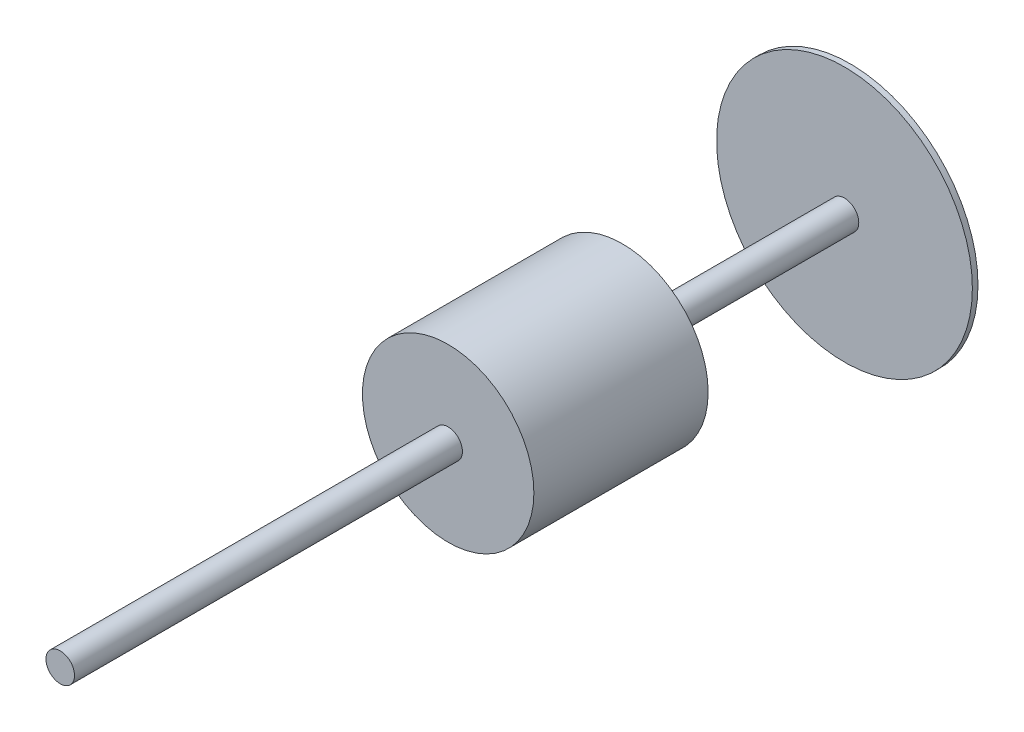
from build123d import *

# Parameters (mm, degrees)
SKETCH1_R                = 50.8
BOSS_EXTRUDE1_DEPTH      = 2130
BOSS_EXTRUDE1_DEPTH_BACK = 680
SKETCH2_R                = 455
BOSS_EXTRUDE2_DEPTH      = 20
BOSS_EXTRUDE3_START      = -1380
SKETCH7_R                = 305
BOSS_EXTRUDE3_DEPTH      = 620
SKETCH8_R                = 225
BOSS_EXTRUDE4_DEPTH      = 50


with BuildPart() as part:
    # Sketch1 → Boss-Extrude1 (new body, two sides)
    with BuildSketch(Plane.XY) as boss_extrude1_sk:
        Circle(SKETCH1_R)
    extrude(amount=BOSS_EXTRUDE1_DEPTH)
    extrude(boss_extrude1_sk.sketch, amount=-BOSS_EXTRUDE1_DEPTH_BACK)

    # Sketch2 → Boss-Extrude2 (add)
    with BuildSketch(Plane.XY.offset(-680)):
        Circle(SKETCH2_R)
    extrude(amount=BOSS_EXTRUDE2_DEPTH)

    # Sketch7 → Boss-Extrude3 (add)
    with BuildSketch(Plane.XY.offset(2130).offset(BOSS_EXTRUDE3_START)):
        Circle(SKETCH7_R)
    extrude(amount=-BOSS_EXTRUDE3_DEPTH)

    # Sketch8 → Boss-Extrude4 (add)
    with BuildSketch(Plane(origin=(0, 0, 130), x_dir=(-1, 0, 0), z_dir=(0, 0, -1))):
        Circle(SKETCH8_R)
    extrude(amount=BOSS_EXTRUDE4_DEPTH)


solid = part.part
